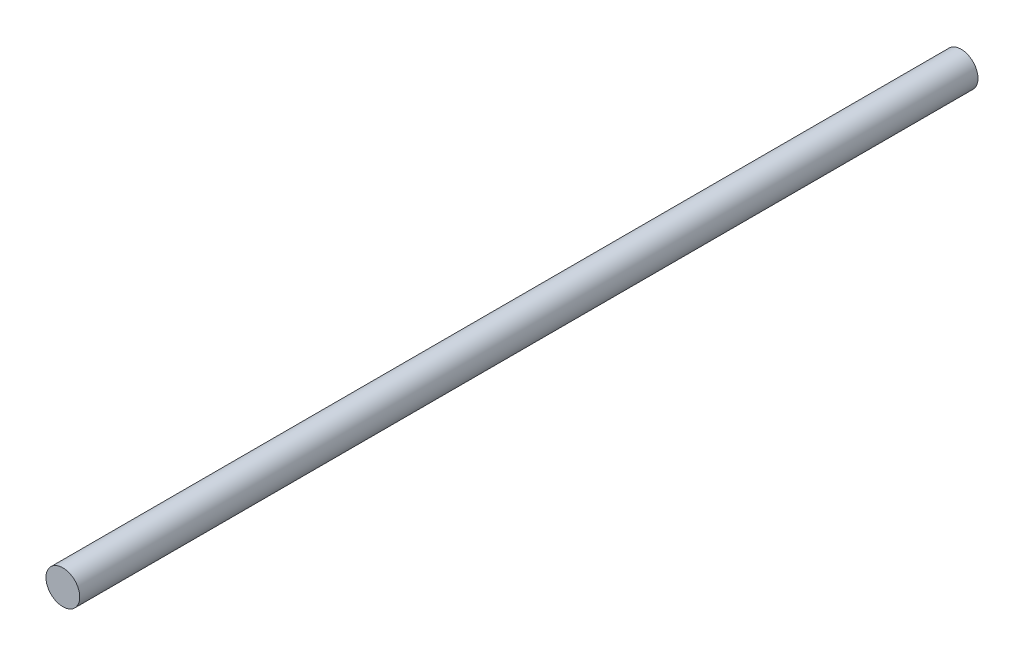
from build123d import *

# Parameters (mm, degrees)
SKETCH1_R           = 5
BOSS_EXTRUDE1_DEPTH = 266


with BuildPart() as part:
    # Sketch1 → Boss-Extrude1 (new body)
    with BuildSketch(Plane.XY):
        with Locations((-8.761117994, 6.924109382)):
            Circle(SKETCH1_R)
    extrude(amount=BOSS_EXTRUDE1_DEPTH)


solid = part.part
